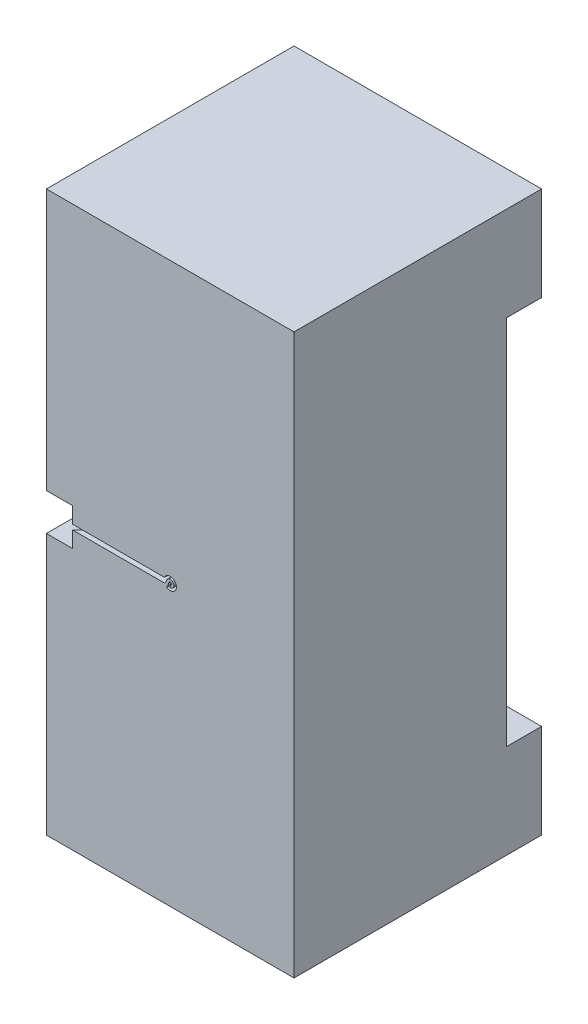
from build123d import *

# Parameters (mm, degrees)
SKETCH1_W           = 100
SKETCH1_H           = 100
BOSS_EXTRUDE1_DEPTH = 226
SKETCH5_W           = 150
SKETCH5_H           = 10
CUT_EXTRUDE2_DEPTH  = 125
SKETCH6_W           = 15
SKETCH6_H           = 15
CUT_EXTRUDE3_DEPTH  = 125
CUT_EXTRUDE6_DEPTH  = 7.5
BOSS_EXTRUDE2_DEPTH = 6.5


with BuildPart() as part:
    # Sketch1 → Boss-Extrude1 (new body)
    with BuildSketch(Plane(origin=(0, 0, 0), x_dir=(1, 0, 0), z_dir=(0, 1, 0))):
        Rectangle(SKETCH1_W, SKETCH1_H)
    extrude(amount=BOSS_EXTRUDE1_DEPTH)

    # Sketch5 → Cut-Extrude2 (cut)
    with BuildSketch(Plane(origin=(50, 0, -50), x_dir=(0, -1, 0), z_dir=(-0.707106781, 0, 0.707106781))):
        with Locations((-113, -5)):
            Rectangle(SKETCH5_W, SKETCH5_H)
        with Locations((-113, 5)):
            Rectangle(SKETCH5_W, SKETCH5_H)
    extrude(amount=CUT_EXTRUDE2_DEPTH, mode=Mode.SUBTRACT)

    # Sketch6 → Cut-Extrude3 (cut)
    with BuildSketch(Plane(origin=(-50, 0, 50), x_dir=(0.707106781, 0, 0.707106781), z_dir=(-0.707106781, 0, 0.707106781))):
        with Locations((0, 113)):
            Rectangle(SKETCH6_W, SKETCH6_H)
    extrude(amount=-CUT_EXTRUDE3_DEPTH, mode=Mode.SUBTRACT)

    # Sketch8 → Cut-Extrude6 (cut)
    with BuildSketch(Plane.XY.offset(50)):
        with BuildLine():
            Line((-39.393398282, 114), (-39.393398282, 112))
            Line((-39.393398282, 112), (-5, 112))
            Line((-5, 112), (-2.291287847, 112))
            ThreePointArc((-2.291287847, 112), (2.5, 113), (-2.291287847, 114))
            Line((-2.291287847, 114), (-5, 114))
            Line((-5, 114), (-39.393398282, 114))
        make_face()
    extrude(amount=-CUT_EXTRUDE6_DEPTH, mode=Mode.SUBTRACT)

    # Sketch10 → Boss-Extrude2 (add)
    with BuildSketch(Plane.XY.offset(50)):
        with BuildLine():
            ThreePointArc((-0.472805429, 113.162650012), (0.407016588, 113.290409189), (0, 112.5))
            Line((0, 112.5), (0, 111.5))
            ThreePointArc((0, 111.5), (1.221049764, 113.871227567), (-1.418416287, 113.487950036))
            ThreePointArc((-1.418416287, 113.487950036), (-1.780506402, 112.700361849), (-2.291287847, 112))
            ThreePointArc((-2.291287847, 112), (-1.928903385, 111.409612711), (-1.418416287, 110.941336541))
            ThreePointArc((-1.418416287, 110.941336541), (-0.906091719, 112.03517002), (-0.472805429, 113.162650012))
        make_face()
    extrude(amount=-BOSS_EXTRUDE2_DEPTH)


solid = part.part
